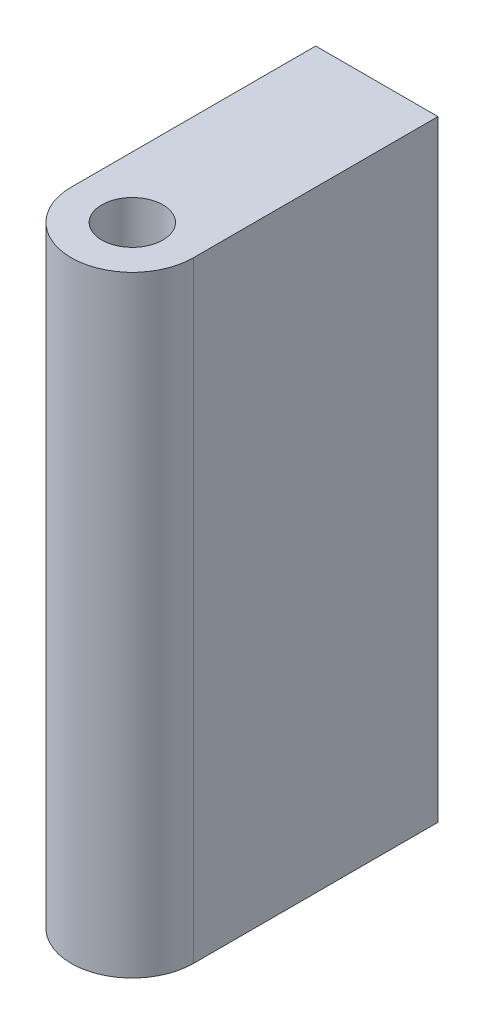
from build123d import *

# Parameters (mm, degrees)
SALIENTE_EXTRUIR1_DEPTH      = 2.5
SALIENTE_EXTRUIR1_DEPTH_BACK = 2.5
CROQUIS1_R                   = 0.25


with BuildPart() as part:
    # Croquis1 → Saliente-Extruir1 (new, two sides: drawn at the far end of the back side and taken through both)
    with BuildSketch(Plane(origin=(0, 0, 0), x_dir=(1, 0, 0), z_dir=(0, 1, 0)).offset(-SALIENTE_EXTRUIR1_DEPTH_BACK)):
        with BuildLine():
            Line((-0.5, 2), (0.5, 2))
            Line((0.5, 2), (0.5, 0))
            ThreePointArc((0.5, 0), (0, -0.5), (-0.5, 0))
            Line((-0.5, 0), (-0.5, 2))
        make_face()
        Circle(CROQUIS1_R, mode=Mode.SUBTRACT)
    extrude(amount=SALIENTE_EXTRUIR1_DEPTH + SALIENTE_EXTRUIR1_DEPTH_BACK)


solid = part.part
